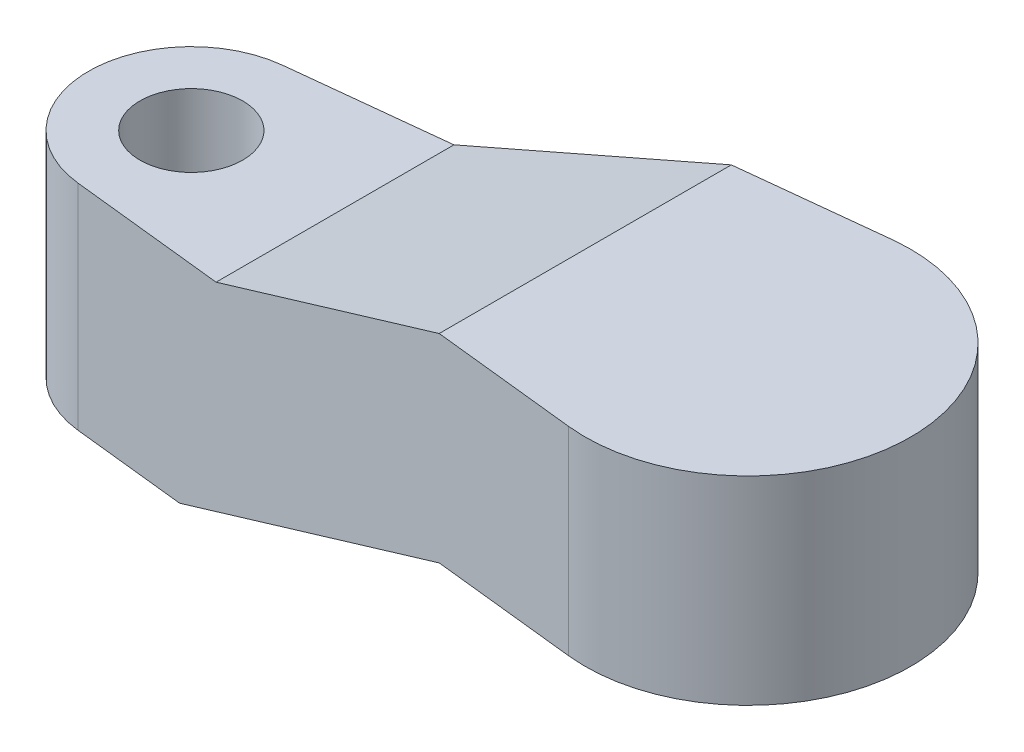
from build123d import *

# Parameters (mm, degrees)
BOSS_EXTRUDE1_DEPTH     = 9
CUT_EXTRUDE1_DEPTH      = 5.75
CUT_EXTRUDE1_DEPTH_BACK = 5.75
SKETCH3_R               = 2
CUT_EXTRUDE2_DEPTH      = 2
SKETCH4_R               = 1.5
CUT_EXTRUDE3_DEPTH      = 10


with BuildPart() as part:
    # Sketch1 → Boss-Extrude1 (new body)
    with BuildSketch(Plane(origin=(0, 0, 0), x_dir=(1, 0, 0), z_dir=(0, 1, 0))):
        with BuildLine():
            Line((-16.573076923, 2.982552816), (-0.511538462, 4.722375292))
            ThreePointArc((-0.511538462, 4.722375292), (4.75, 0), (-0.511538462, -4.722375292))
            Line((-0.511538462, -4.722375292), (-16.573076923, -2.982552816))
            ThreePointArc((-16.573076923, -2.982552816), (-19.25, 0), (-16.573076923, 2.982552816))
        make_face()
    extrude(amount=BOSS_EXTRUDE1_DEPTH)

    # Sketch2 → Cut-Extrude1 (cut, two sides)
    with BuildSketch(Plane.XY) as cut_extrude1_sk:
        Polygon((-4.75, 9), (-12.0546875, 6.25), (-19.25, 6.25), (-19.25, 9), align=None)
        Polygon((-13.25, 0), (-4.75, 3.2), (4.75, 3.2), (4.75, 0), align=None)
    extrude(amount=CUT_EXTRUDE1_DEPTH, mode=Mode.SUBTRACT)
    extrude(cut_extrude1_sk.sketch, amount=-CUT_EXTRUDE1_DEPTH_BACK, mode=Mode.SUBTRACT)

    # Sketch3 → Cut-Extrude2 (cut)
    with BuildSketch(Plane.XZ.offset(-3.2)):
        Circle(SKETCH3_R)
    extrude(amount=-CUT_EXTRUDE2_DEPTH, mode=Mode.SUBTRACT)

    # Sketch4 → Cut-Extrude3 (cut, through all)
    with BuildSketch(Plane.XZ):
        with Locations((-16.25, 0)):
            Circle(SKETCH4_R)
    extrude(amount=-CUT_EXTRUDE3_DEPTH, mode=Mode.SUBTRACT)


solid = part.part
